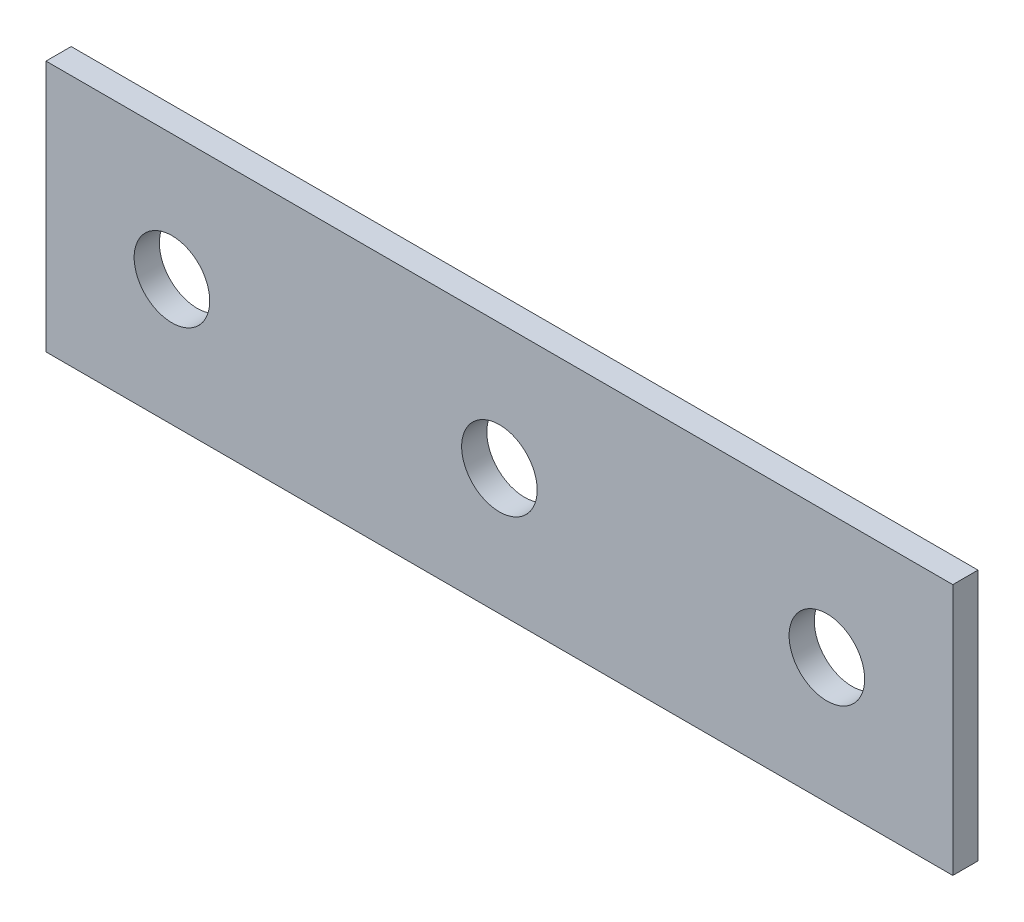
from build123d import *

# Parameters (mm, degrees)
SKETCH1_W           = 228.6
SKETCH1_H           = 63.5
BOSS_EXTRUDE1_DEPTH = 6.35
SKETCH2_R           = 9.525
CUT_EXTRUDE1_DEPTH  = 7.35
LPATTERN1_COUNT     = 3
LPATTERN1_PITCH     = 82.55


with BuildPart() as part:
    # Sketch1 → Boss-Extrude1 (new body)
    with BuildSketch(Plane.XY):
        Rectangle(SKETCH1_W, SKETCH1_H)
    extrude(amount=BOSS_EXTRUDE1_DEPTH)

    # Sketch2 → Cut-Extrude1 (cut, through all)
    with BuildSketch(Plane.XY.offset(6.35)):
        with Locations((-82.55, 0)):
            Circle(SKETCH2_R)
    cut_extrude1 = extrude(amount=-CUT_EXTRUDE1_DEPTH, mode=Mode.SUBTRACT)

    # LPattern1: Cut-Extrude1 ×3
    with Locations(*[(i * LPATTERN1_PITCH, 0, 0) for i in range(1, LPATTERN1_COUNT)]):
        add(cut_extrude1, mode=Mode.SUBTRACT)


solid = part.part
